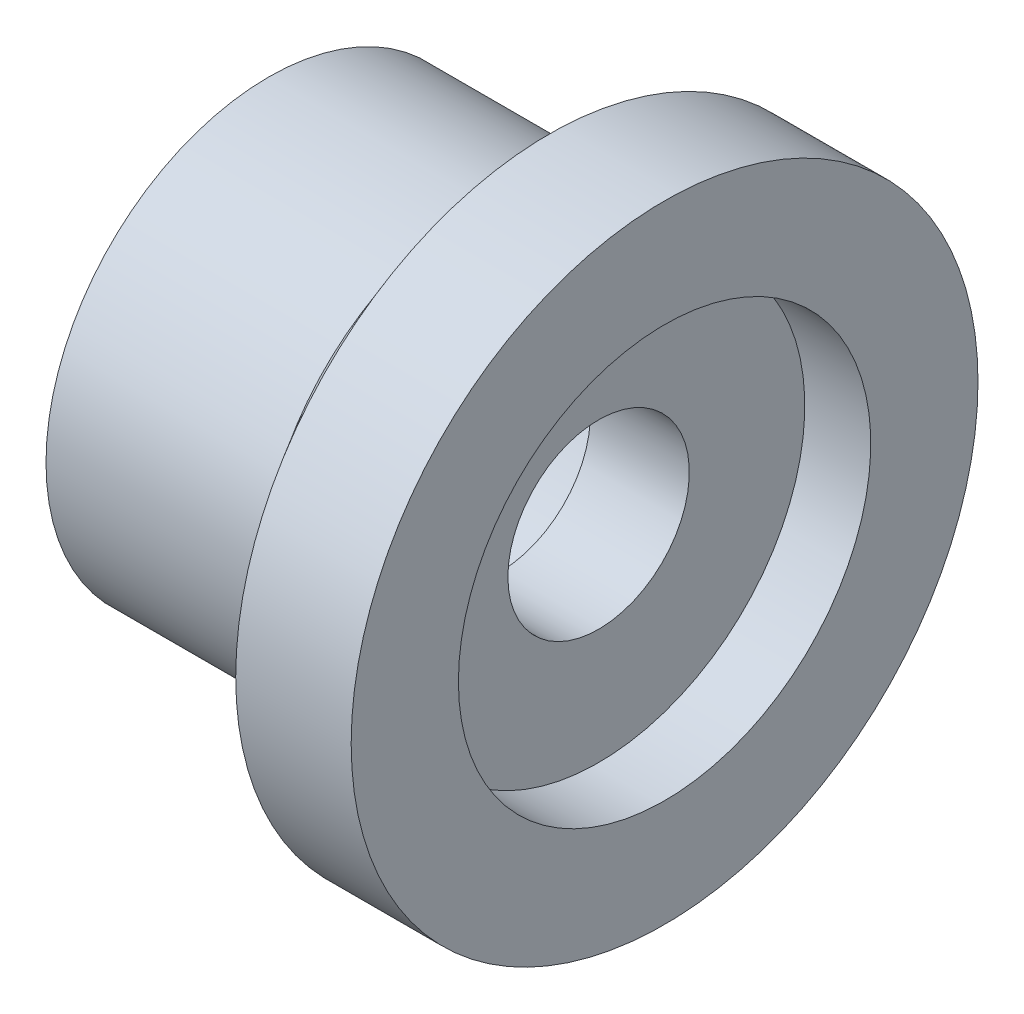
from build123d import *


with BuildPart() as part:
    # Esquisse1 → Révolution1 (revolve)
    with BuildSketch(Plane.XY, mode=Mode.PRIVATE) as r_volution1_sk:
        Polygon((-5, 2.75), (-2, 2.75), (-2, 6.25), (0, 6.25), (0, 9.5), (-3.5, 9.5), (-5.5, 6.75), (-12, 6.75), (-12, 5.25), (-5, 5.25), align=None)
    revolve(r_volution1_sk.sketch.rotate(Axis((-19.911160568, 0, 0), (1, 0, 0)), 90), axis=Axis((-19.911160568, 0, 0), (1, 0, 0)))  # turned: the seam where the file's is


solid = part.part
